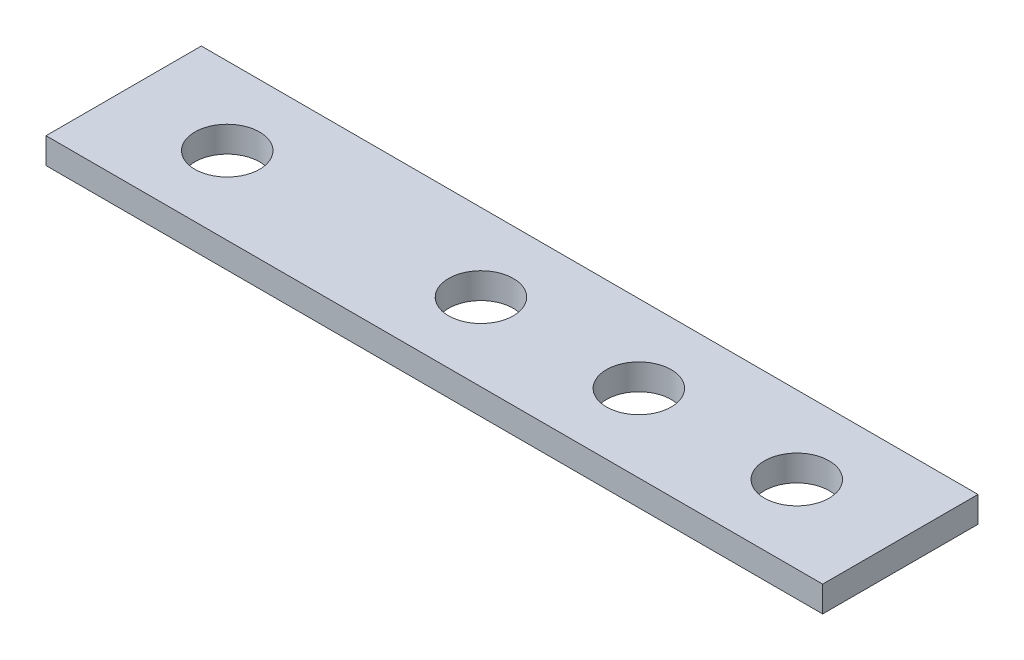
from build123d import *

# Parameters (mm, degrees)
SKETCH1_W             = 60
SKETCH1_H             = 12
BOSS_EXTRUDE1_DEPTH   = 2
F_5_0MM_DOWEL_HOLE1_D = 5


with BuildPart() as part:
    # Sketch1 → Boss-Extrude1 (new body)
    with BuildSketch(Plane(origin=(0, 0, 0), x_dir=(1, 0, 0), z_dir=(0, 1, 0))):
        Rectangle(SKETCH1_W, SKETCH1_H)
    extrude(amount=BOSS_EXTRUDE1_DEPTH)

    # Ø5.0mm Dowel Hole1 (through all)
    with Locations(Plane(origin=(0, 2, 0), x_dir=(1, 0, 0), z_dir=(0, 1, 0))):
        with Locations((22, 0), (9.8, 0), (-2.4, 0), (-22, 0)):
            Hole(F_5_0MM_DOWEL_HOLE1_D / 2)


solid = part.part
